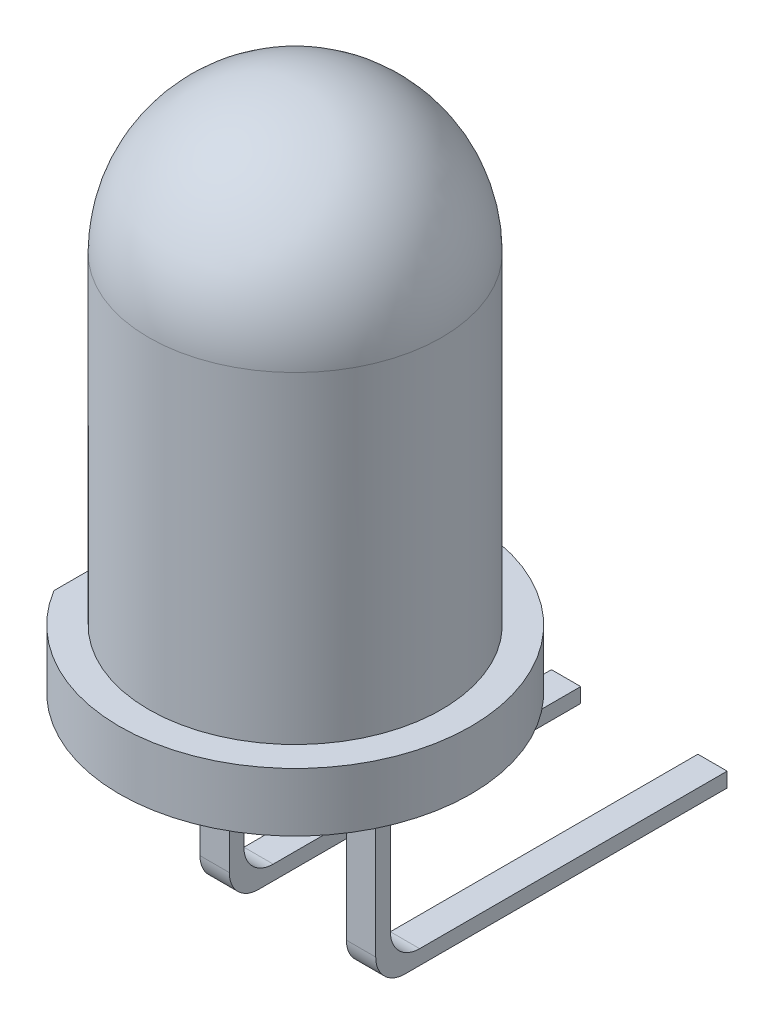
from build123d import *

# Parameters (mm, degrees)
SKETCH2_W           = 0.5
SKETCH2_H           = 0.25
EXTRUDE1_DEPTH      = 30
SKETCH3_W           = 0.5
SKETCH3_H           = 10
EXTRUDE3_DEPTH      = 2
EXTRUDE3_DEPTH_BACK = 2
SKETCH4_W           = 0.5
SKETCH4_H           = 3.5
EXTRUDE4_DEPTH      = 2
BOSS_EXTRUDE1_DEPTH = 3
CUT_EXTRUDE1_DEPTH  = 10
FILLET1_R           = 0.5


with BuildPart() as part:
    # Sketch1 → Revolve1 (revolve)
    with BuildSketch(Plane.XY):
        with BuildLine():
            Line((0, 2.5), (0, -5.5))
            Line((0, -5.5), (0, -6.5))
            Line((0, -6.5), (3, -6.5))
            Line((3, -6.5), (3, -5.5))
            Line((3, -5.5), (2.5, -5.5))
            Line((2.5, -5.5), (2.5, 0))
            ThreePointArc((2.5, 0), (1.767766953, 1.767766953), (0, 2.5))
        make_face()
    revolve(axis=Axis((0, 40.48125, 0), (0, -1, 0)))

    # Sketch2 → Extrude1 (add)
    with BuildSketch(Plane.XZ.offset(6.5)):
        with Locations((1.25, 0)):
            Rectangle(SKETCH2_W, SKETCH2_H)
        with Locations((-1.25, 0)):
            Rectangle(SKETCH2_W, SKETCH2_H)
    extrude(amount=EXTRUDE1_DEPTH)

    # Sketch3 → Extrude3 (cut, two sides)
    with BuildSketch(Plane.XY) as extrude3_sk:
        with Locations((-1.25, -31.5)):
            Rectangle(SKETCH3_W, SKETCH3_H)
    extrude(amount=EXTRUDE3_DEPTH, mode=Mode.SUBTRACT)
    extrude(extrude3_sk.sketch, amount=-EXTRUDE3_DEPTH_BACK, mode=Mode.SUBTRACT)

    # Sketch4 → Extrude4 (cut)
    with BuildSketch(Plane.XZ.offset(6.5)):
        with Locations((-2.817517664, 0)):
            Rectangle(SKETCH4_W, SKETCH4_H)
    extrude(amount=-EXTRUDE4_DEPTH, mode=Mode.SUBTRACT)

    # Sketch5 → Boss-Extrude1 (add)
    with BuildSketch(Plane.ZY.offset(1.5)):
        Polygon((0.125, -10.097548576), (-5.875, -10.097548576), (-5.875, -9.847548576), (-0.125, -9.847548576), align=None)
    extrude(amount=-BOSS_EXTRUDE1_DEPTH)

    # Sketch6 → Cut-Extrude1 (cut)
    with BuildSketch(Plane.XY.offset(0.125)):
        Polygon((-1, -8.951862253), (1, -8.951862253), (1, -10.097548576), (1.5, -10.097548576), (1.5, -37.452172459), (-1.5, -37.452172459), (-1.5, -10.097548576), (-1, -10.097548576), align=None)
    extrude(amount=-CUT_EXTRUDE1_DEPTH, mode=Mode.SUBTRACT)

    # Fillet1
    fillet1_edges = [part.edges().sort_by_distance(p)[0] for p in [
        (1.25, -10.097548576, 0.125),
        (-1.25, -10.097548576, 0.125),
        (-1.25, -9.847548576, -0.125),
        (1.25, -9.847548576, -0.125),
    ]]
    fillet(fillet1_edges, radius=FILLET1_R)


solid = part.part
